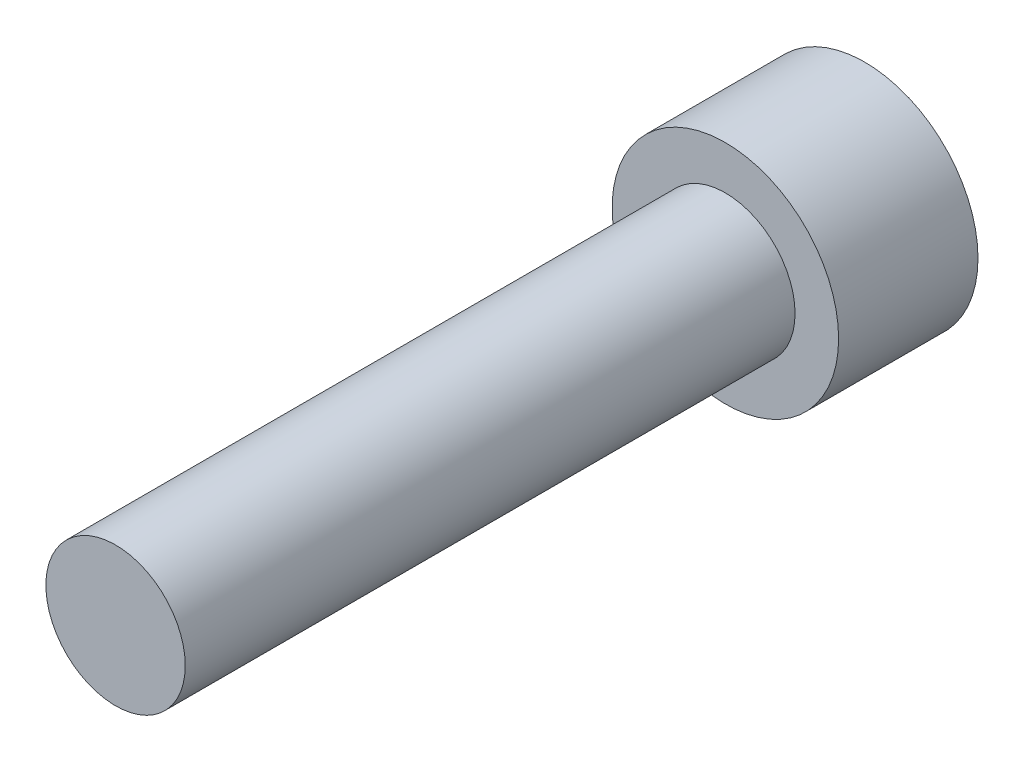
from build123d import *

# Parameters (mm, degrees)
SKETCH_1_R      = 6.5
EXTRUDE_1_DEPTH = 8
SKETCH_2_R      = 4
EXTRUDE_2_DEPTH = 35


with BuildPart() as part:
    # 草图1 → 凸台-拉伸1 (new body)
    with BuildSketch(Plane.XY):
        with Locations((-10.158870923, 10.242140357)):
            Circle(SKETCH_1_R)
    extrude(amount=EXTRUDE_1_DEPTH)

    # 草图2 → 凸台-拉伸2 (add)
    with BuildSketch(Plane.XY.offset(8)):
        with Locations((-10.158870923, 10.242140357)):
            Circle(SKETCH_2_R)
    extrude(amount=EXTRUDE_2_DEPTH)


solid = part.part
